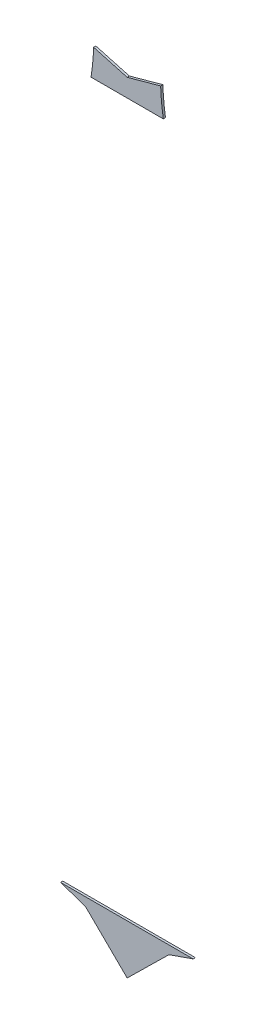
from build123d import *

# Parameters (mm, degrees)
SALIENTE_EXTRUIR1_DEPTH   = 0.1
SALIENTE_EXTRUIR1_2_DEPTH = 0.1


with BuildPart() as part:
    # Model → Saliente-Extruir1 (new body)
    with BuildSketch(Plane.XY):
        Polygon((39.265808306, -0.911572929), (33.311070818, -0.911572929), (34.426407672, -1.291216959), (36.301941466, -3.135018824), (38.177300109, -1.291038811), align=None)
    extrude(amount=SALIENTE_EXTRUIR1_DEPTH)


with BuildPart() as body_2:
    # Model → Saliente-Extruir1 2 (new body)
    with BuildSketch(Plane.XY):
        with BuildLine():
            Line((34.677881776, 31.088427071), (37.922774876, 31.088427071))
            ThreePointArc((37.922774876, 31.088427071), (37.844578192, 31.69749464), (37.803876403, 32.310211043))
            Line((37.803876403, 32.310211043), (36.301776991, 31.895347329))
            Line((36.301776991, 31.895347329), (34.796639594, 32.310068214))
            ThreePointArc((34.796639594, 32.310068214), (34.756003558, 31.697425616), (34.677881776, 31.088427071))
        make_face()
    extrude(amount=SALIENTE_EXTRUIR1_2_DEPTH)


solid = Compound([part.part, body_2.part])
